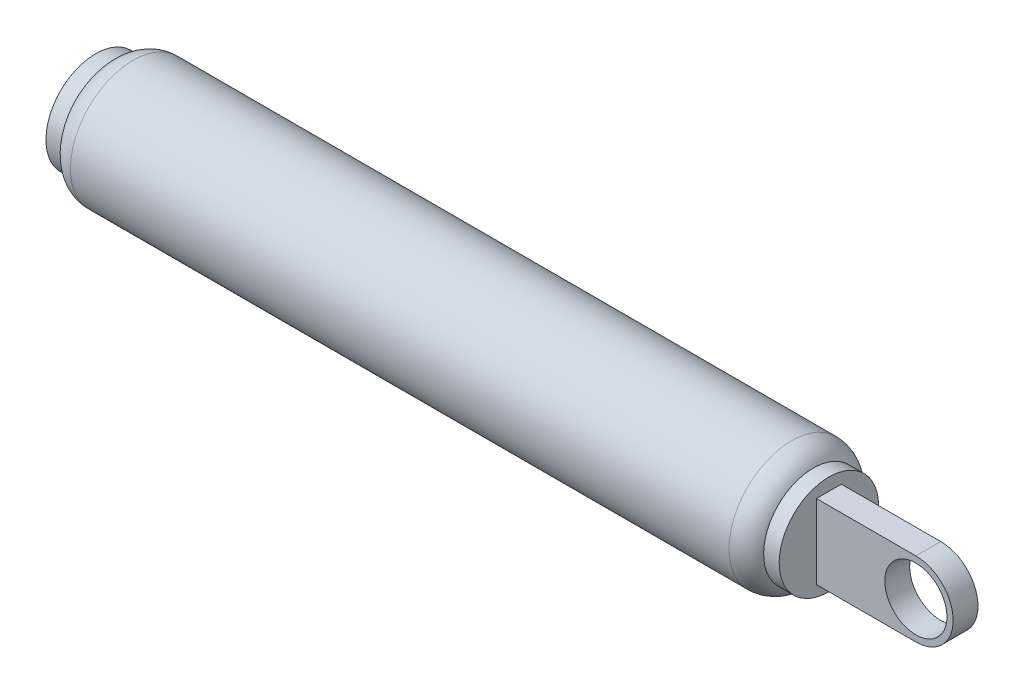
from build123d import *

# Parameters (mm, degrees)
BOSS_EXTRUDE1_DEPTH          = 2
F_6_0_6_DIAMETER_HOLE1_D     = 6
F_6_0_6_DIAMETER_HOLE1_DEPTH = 30
F_5_0_5_DIAMETER_HOLE1_D     = 5
F_5_0_5_DIAMETER_HOLE1_DEPTH = 6.031754163


with BuildPart() as part:
    # Sketch1 → Revolve1 (revolve)
    with BuildSketch(Plane(origin=(0, 0, 0), x_dir=(-1, 0, 0), z_dir=(0, 0, -1))):
        with BuildLine():
            Line((-29.5, 4), (-29.5, 0))
            Line((-29.5, 0), (29.5, 0))
            Line((29.5, 0), (29.5, 4))
            Line((29.5, 4), (28.25, 4))
            ThreePointArc((28.25, 4), (27.515753003, 4.754613948), (26.5, 5.031754163))
            Line((26.5, 5.031754163), (-26.5, 5.031754163))
            ThreePointArc((-26.5, 5.031754163), (-27.515753003, 4.754613948), (-28.25, 4))
            Line((-28.25, 4), (-29.5, 4))
        make_face()
    revolve(axis=Axis((29.5, 0, 0), (-1, 0, 0)))

    # Sketch2 → Boss-Extrude1 (add)
    with BuildSketch(Plane.XY.offset(1)):
        with BuildLine():
            Line((37.5, 3), (29.5, 3))
            Line((29.5, 3), (29.5, -3))
            Line((29.5, -3), (37.5, -3))
            ThreePointArc((37.5, -3), (40.5, 0), (37.5, 3))
        make_face()
    extrude(amount=-BOSS_EXTRUDE1_DEPTH)

    # Ø6.0 (6) Diameter Hole1
    with Locations(Plane.ZY.offset(29.5)):
        with Locations((0, 0)):
            Hole(F_6_0_6_DIAMETER_HOLE1_D / 2, depth=F_6_0_6_DIAMETER_HOLE1_DEPTH)

    # Ø5.0 (5) Diameter Hole1
    with Locations(Plane(origin=(0, 0, -1), x_dir=(-1, 0, 0), z_dir=(0, 0, -1))):
        with Locations((-37.5, 0)):
            Hole(F_5_0_5_DIAMETER_HOLE1_D / 2, depth=F_5_0_5_DIAMETER_HOLE1_DEPTH)


solid = part.part
